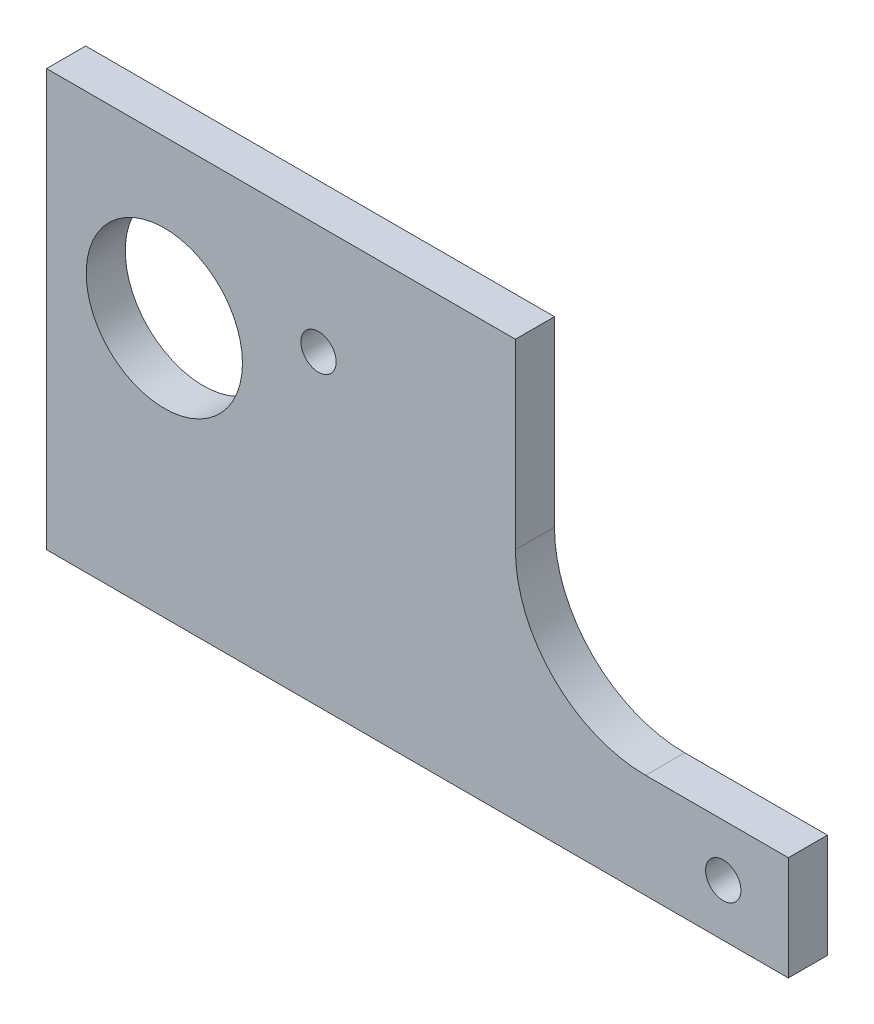
from build123d import *

# Parameters (mm, degrees)
BOSS_EXTRUDE1_DEPTH         = 4.7625
F_3_4_0_75_DIAMETER_HOLE1_D = 19.05
F_6_CLEARANCE_HOLE1_D       = 4.3053


with BuildPart() as part:
    # Sketch1 → Boss-Extrude1 (new body)
    with BuildSketch(Plane.XY):
        with BuildLine():
            Line((93.599, -41.275), (76.2, -41.275))
            ThreePointArc((76.2, -41.275), (64.974679849, -36.625320151), (60.325, -25.4))
            Line((60.325, -25.4), (60.325, -3.175))
            Line((60.325, -3.175), (3.175, -3.175))
            Line((3.175, -3.175), (3.175, -53.975))
            Line((3.175, -53.975), (93.599, -53.975))
            Line((93.599, -53.975), (93.599, -41.275))
        make_face()
    extrude(amount=BOSS_EXTRUDE1_DEPTH)

    # 3/4 (0.75) Diameter Hole1 (through all)
    with Locations(Plane.XY.offset(4.7625)):
        with Locations((17.526, -22.352)):
            Hole(F_3_4_0_75_DIAMETER_HOLE1_D / 2)

    # #6 Clearance Hole1 (through all)
    with Locations(Plane.XY.offset(4.7625)):
        with Locations((36.322, -16.51), (85.6615, -47.625)):
            Hole(F_6_CLEARANCE_HOLE1_D / 2)


solid = part.part
